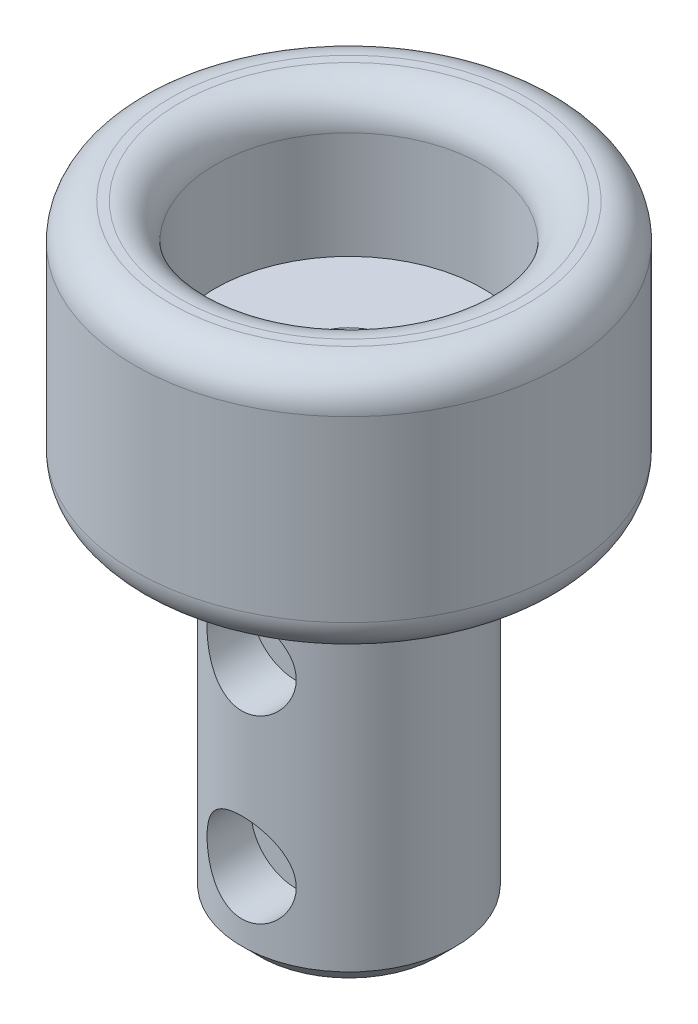
from build123d import *

# Parameters (mm, degrees)
SKIZZE1_R                       = 6
AUFSATZ_LINEAR_AUSTRAGEN1_DEPTH = 7
SKIZZE2_R                       = 3.75
SCHNITT_LINEAR_AUSTRAGEN1_DEPTH = 4
SKIZZE3_R                       = 1
SCHNITT_LINEAR_AUSTRAGEN2_DEPTH = 4
AUFSATZ_LINEAR_START            = 0.1
SKIZZE5_R                       = 3
SKIZZE5_R_2                     = 1
AUFSATZ_LINEAR_AUSTRAGEN2_DEPTH = 10
SCHNITT_LINEAR_START            = 1.5
SKIZZE6_R                       = 1.25
SCHNITT_LINEAR_AUSTRAGEN3_DEPTH = 10
VERRUNDUNG1_R                   = 1
FASE1_SIZE                      = 0.5
FASE2_SIZE                      = 0.3


with BuildPart() as part:
    # Skizze1 → Aufsatz-Linear austragen1 (new body)
    with BuildSketch(Plane(origin=(0, 0, 0), x_dir=(1, 0, 0), z_dir=(0, 1, 0))):
        Circle(SKIZZE1_R)
    extrude(amount=AUFSATZ_LINEAR_AUSTRAGEN1_DEPTH)

    # Skizze2 → Schnitt-Linear austragen1 (cut)
    with BuildSketch(Plane(origin=(0, 7, 0), x_dir=(1, 0, 0), z_dir=(0, 1, 0))):
        Circle(SKIZZE2_R)
    extrude(amount=-SCHNITT_LINEAR_AUSTRAGEN1_DEPTH, mode=Mode.SUBTRACT)

    # Skizze3 → Schnitt-Linear austragen2 (cut)
    with BuildSketch(Plane(origin=(0, 3, 0), x_dir=(1, 0, 0), z_dir=(0, 1, 0))):
        Circle(SKIZZE3_R)
    extrude(amount=-SCHNITT_LINEAR_AUSTRAGEN2_DEPTH, mode=Mode.SUBTRACT)

    # Verrundung1
    verrundung1_edges = [part.edges().sort_by_distance(p)[0] for p in [
        (-6, 0, 0),
        (-6, 7, 0),
        (-3.75, 7, 0),
    ]]
    fillet(verrundung1_edges, radius=VERRUNDUNG1_R)

    # Fase2
    fase2_edges = [part.edges().sort_by_distance(p)[0] for p in [
        (-1, 0, 0),
        (-1, 3, 0),
    ]]
    chamfer(fase2_edges, length=FASE2_SIZE)


with BuildPart() as body_2:
    # Skizze5 → Aufsatz-Linear austragen2 (new body)
    with BuildSketch(Plane.XZ.offset(AUFSATZ_LINEAR_START)):
        Circle(SKIZZE5_R)
        Circle(SKIZZE5_R_2, mode=Mode.SUBTRACT)
    extrude(amount=AUFSATZ_LINEAR_AUSTRAGEN2_DEPTH)

    # Skizze6 → Schnitt-Linear austragen3 (cut)
    with BuildSketch(Plane.XY.offset(SCHNITT_LINEAR_START)):
        with Locations((0, -2.635386332)):
            Circle(SKIZZE6_R)
        with Locations((0, -7.684738109)):
            Circle(SKIZZE6_R)
    extrude(amount=SCHNITT_LINEAR_AUSTRAGEN3_DEPTH, mode=Mode.SUBTRACT)

    # Fase1
    fase1_edges = [body_2.edges().sort_by_distance(p)[0] for p in [
        (-3, -0.1, 0),
        (-3, -10.1, 0),
    ]]
    chamfer(fase1_edges, length=FASE1_SIZE)


solid = Compound([part.part, body_2.part])
